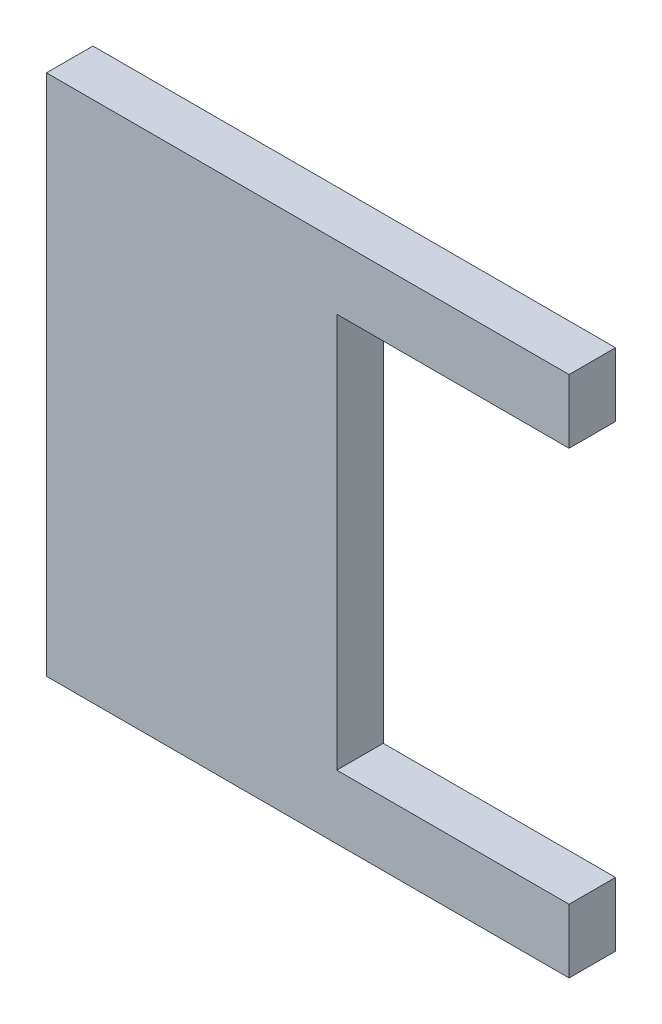
from build123d import *

# Parameters (mm, degrees)
P_IDAT_VYSUNUT_M1_DEPTH = 8


with BuildPart() as part:
    # Skica1 → Přidat vysunutím1 (new body)
    with BuildSketch(Plane.XY):
        Polygon((0, 0), (0, 90), (90, 90), (90, 79), (50, 79), (50, 11), (90, 11), (90, 0), align=None)
    extrude(amount=P_IDAT_VYSUNUT_M1_DEPTH)


solid = part.part
